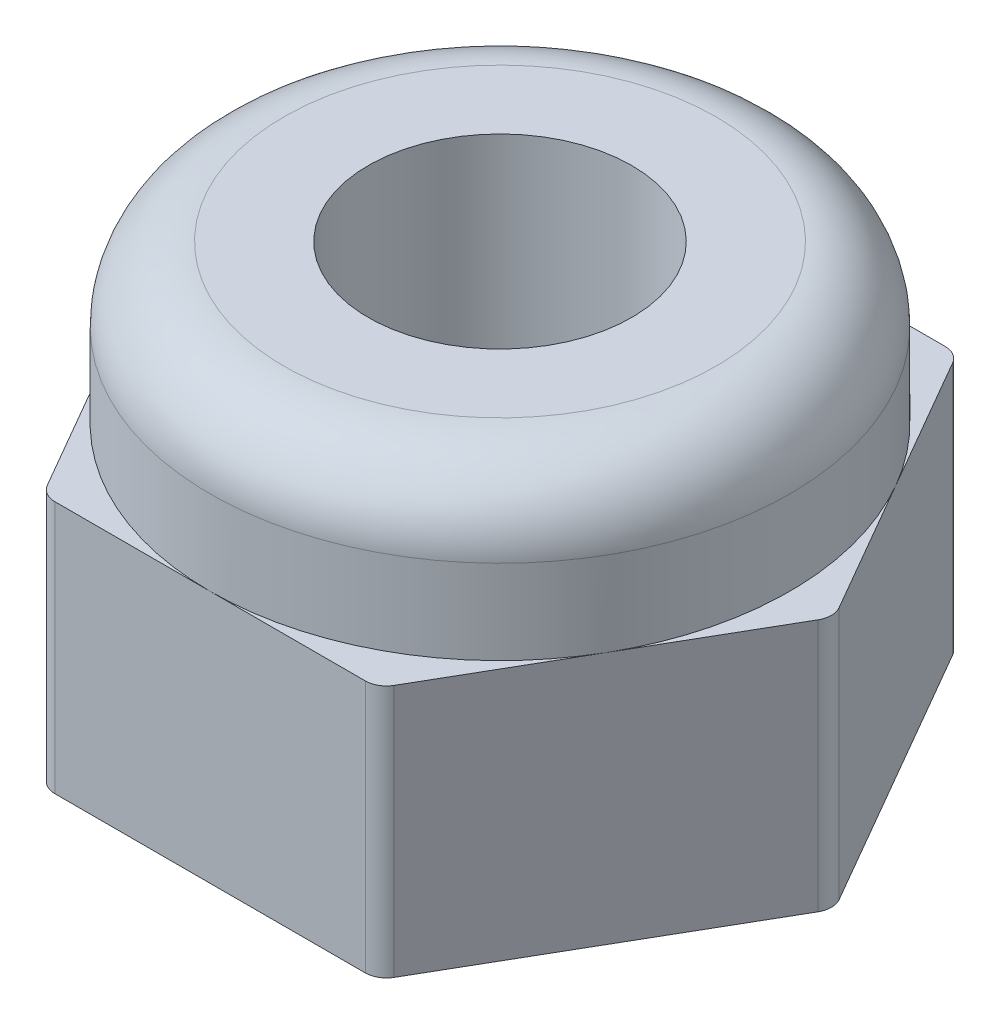
from build123d import *

# Parameters (mm, degrees)
BOSS_EXTRUDE1_DEPTH = 2.4
SKETCH2_R           = 2.75
BOSS_EXTRUDE2_DEPTH = 3.9
FILLET1_R           = 0.7
FILLET2_R           = 0.2
M3_TAPPED_HOLE1_D   = 2.5


with BuildPart() as part:
    # Sketch1 → Boss-Extrude1 (new body)
    with BuildSketch(Plane(origin=(0, 0, 0), x_dir=(1, 0, 0), z_dir=(0, 1, 0))):
        Polygon((3.175426481, 0), (1.58771324, 2.75), (-1.58771324, 2.75), (-3.175426481, 0), (-1.58771324, -2.75), (1.58771324, -2.75), align=None)
    extrude(amount=BOSS_EXTRUDE1_DEPTH)

    # Sketch2 → Boss-Extrude2 (add)
    with BuildSketch(Plane.XZ):
        Circle(SKETCH2_R)
    extrude(amount=-BOSS_EXTRUDE2_DEPTH)

    # Fillet1
    fillet1_edges = [part.edges().sort_by_distance(p)[0] for p in [
        (-2.75, 3.9, 0),
    ]]
    fillet(fillet1_edges, radius=FILLET1_R)

    # Fillet2
    fillet2_edges = [part.edges().sort_by_distance(p)[0] for p in [
        (1.58771324, 1.2, 2.75),
        (-1.58771324, 1.2, 2.75),
        (-3.175426481, 1.2, 0),
        (-1.58771324, 1.2, -2.75),
        (1.58771324, 1.2, -2.75),
        (3.175426481, 1.2, 0),
    ]]
    fillet(fillet2_edges, radius=FILLET2_R)

    # M3 Tapped Hole1 (through all)
    with Locations(Plane(origin=(0, 0, 0), x_dir=(-1, 0, 0), z_dir=(0, -1, 0))):
        with Locations((0, 0)):
            Hole(M3_TAPPED_HOLE1_D / 2)


solid = part.part
